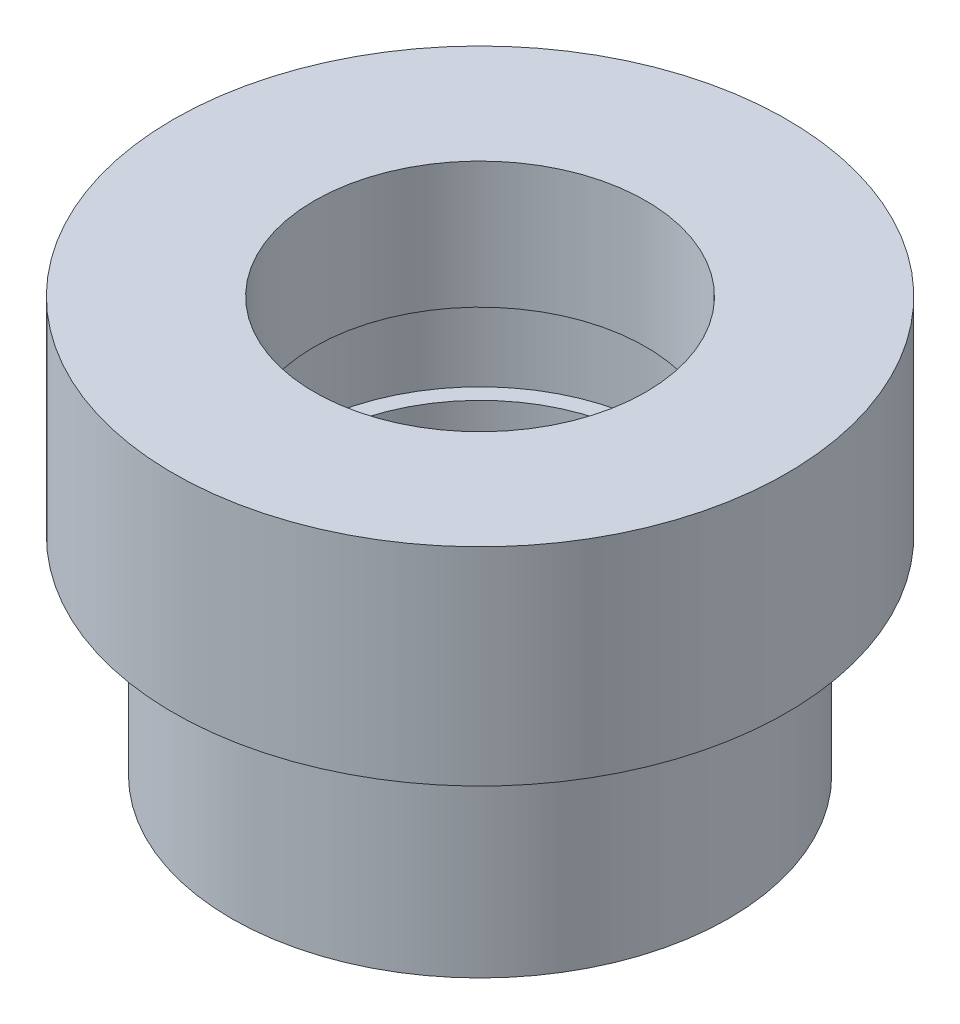
from build123d import *


with BuildPart() as part:
    # Sketch6 → Revolve2 (revolve)
    with BuildSketch(Plane.XY):
        Polygon((-84.317460317, 64.670939731), (-84.317460317, 39.670939731), (-77.317460317, 39.670939731), (-77.317460317, 14.670939731), (-67.317460317, 14.670939731), (-67.317460317, 39.670939731), (-69.317460317, 39.670939731), (-69.317460317, 49.404761905), (-67.317460317, 49.404761905), (-67.317460317, 64.670939731), align=None)
    revolve(axis=Axis((-47.317460317, 64.670939731, 0), (0, -1, 0)))


solid = part.part
